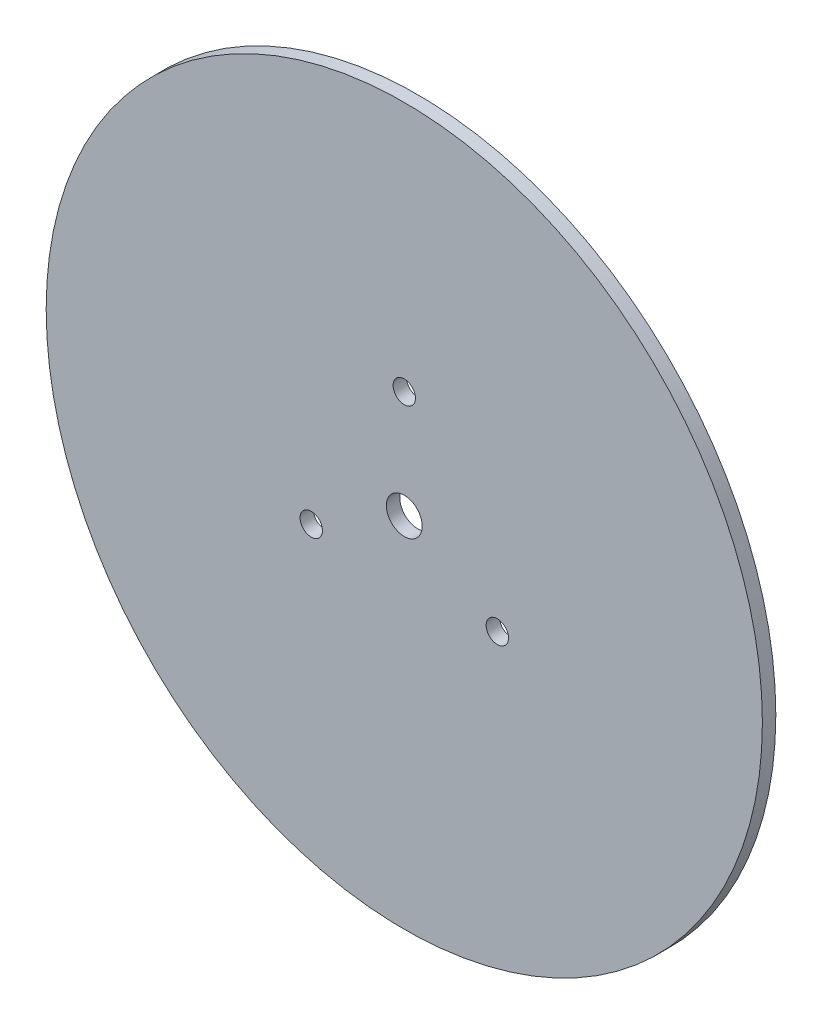
from build123d import *

# Parameters (mm, degrees)
SKETCH2_R           = 80
SKETCH2_R_2         = 4
BOSS_EXTRUDE1_DEPTH = 3
SKETCH5_R           = 2.5
CUT_EXTRUDE1_DEPTH  = 10


with BuildPart() as part:
    # Sketch2 → Boss-Extrude1 (new body)
    with BuildSketch(Plane.XY):
        Circle(SKETCH2_R)
        Circle(SKETCH2_R_2, mode=Mode.SUBTRACT)
    extrude(amount=BOSS_EXTRUDE1_DEPTH)

    # Sketch5 → Cut-Extrude1 (cut)
    with BuildSketch(Plane.XY.offset(3)):
        with Locations((0, 24)):
            Circle(SKETCH5_R)
        with Locations((20.784609691, -12)):
            Circle(SKETCH5_R)
        with Locations((-20.784609691, -12)):
            Circle(SKETCH5_R)
    extrude(amount=-CUT_EXTRUDE1_DEPTH, mode=Mode.SUBTRACT)


solid = part.part
